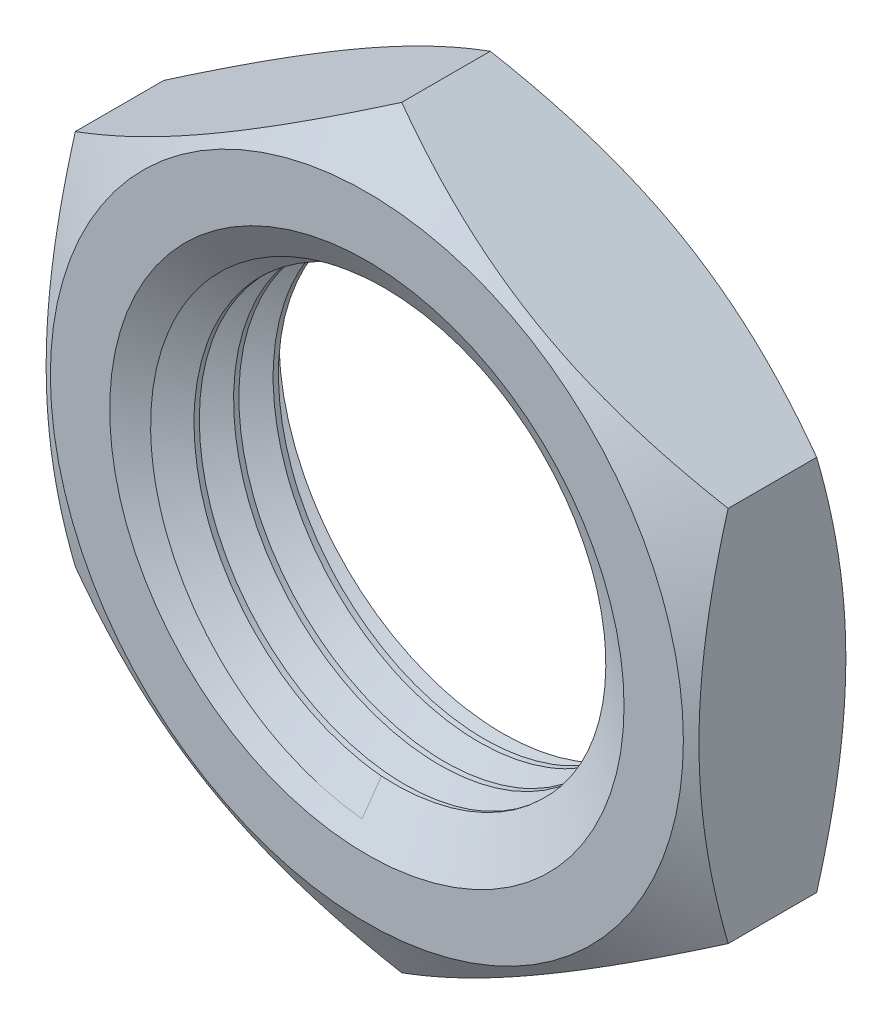
from build123d import *

# Parameters (mm, degrees)
SKETCH_1_W          = 4
SKETCH_1_H          = 5.45
SKETCH_2_R          = 11
CUT_EXTRUDE_1_DEPTH = 16.72021
SKETCH_3_W          = 6
SKETCH_3_H          = 8.964102
SWEEP_1_PITCH       = 1
SWEEP_1_HEIGHT      = 10
SWEEP_1_RADIUS      = 6.05
SWEEP_1_START_ANGLE = 180


with BuildPart() as part:
    # Эскиз1 → Повернуть1 (revolve)
    with BuildSketch(Plane(origin=(0, 0, 0), x_dir=(0, 0, -1), z_dir=(1, 0, 0)), mode=Mode.PRIVATE) as revolve_1_sk:
        with Locations((2, 8.025)):
            Rectangle(SKETCH_1_W, SKETCH_1_H)
    revolve(revolve_1_sk.sketch.rotate(Axis((0, 0, 0), (0, 0, -1)), 90), axis=Axis((0, 0, 0), (0, 0, -1)))

    # Эскиз2 → Вырез-Вытянуть1 (cut, through all)
    with BuildSketch(Plane.XY):
        Circle(SKETCH_2_R)
        Polygon((8.25, -4.76314), (8.25, 4.76314), (0, 9.526279), (-8.25, 4.76314), (-8.25, -4.76314), (0, -9.526279), align=None, mode=Mode.SUBTRACT)
    extrude(amount=-CUT_EXTRUDE_1_DEPTH, mode=Mode.SUBTRACT)

    # Эскиз3 → Вырез-Повернуть1 (revolve, cut)
    with BuildSketch(Plane(origin=(0, 0, 0), x_dir=(0, 0, -1), z_dir=(1, 0, 0)), mode=Mode.PRIVATE) as cut_revolve_1_sk:
        with Locations((2, 6.517949)):
            Rectangle(SKETCH_3_W, SKETCH_3_H)
        Polygon((2, 3.035898), (4, 6.5), (4, 8), (2.845299, 10), (1.154701, 10), (0, 8), (0, 6.5), align=None, mode=Mode.SUBTRACT)
    revolve(cut_revolve_1_sk.sketch.rotate(Axis((0, 0, 0), (0, 0, -1)), 240), axis=Axis((0, 0, 0), (0, 0, -1)), mode=Mode.SUBTRACT)

    # Вырез-По траектории1: sweep along a helix
    with BuildLine() as sweep_1_path:
        add(Helix(SWEEP_1_PITCH, SWEEP_1_HEIGHT, SWEEP_1_RADIUS, center=(0, 0, -4), direction=(0, 0, 1), mode=Mode.PRIVATE).rotate(Axis((0, 0, -4), (0, 0, 1)), SWEEP_1_START_ANGLE))
    with BuildLine() as sweep_1_axis:
        Line((0, 0, -4), (0, 0, 6))
    # Эскиз5 → Вырез-По траектории1 (sweep, cut)
    with BuildSketch(Plane(origin=(-6.05, 0, -4), x_dir=(-1, 0, 0), z_dir=(0, -0.9996541608311538, 0.026297504310521795))):
        Polygon((-0.861695, 0.9975), (0, 0.5), (-0.861695, 0.0025), align=None)
    sweep(path=sweep_1_path.line, binormal=sweep_1_axis.edges()[0], mode=Mode.SUBTRACT)


solid = part.part
